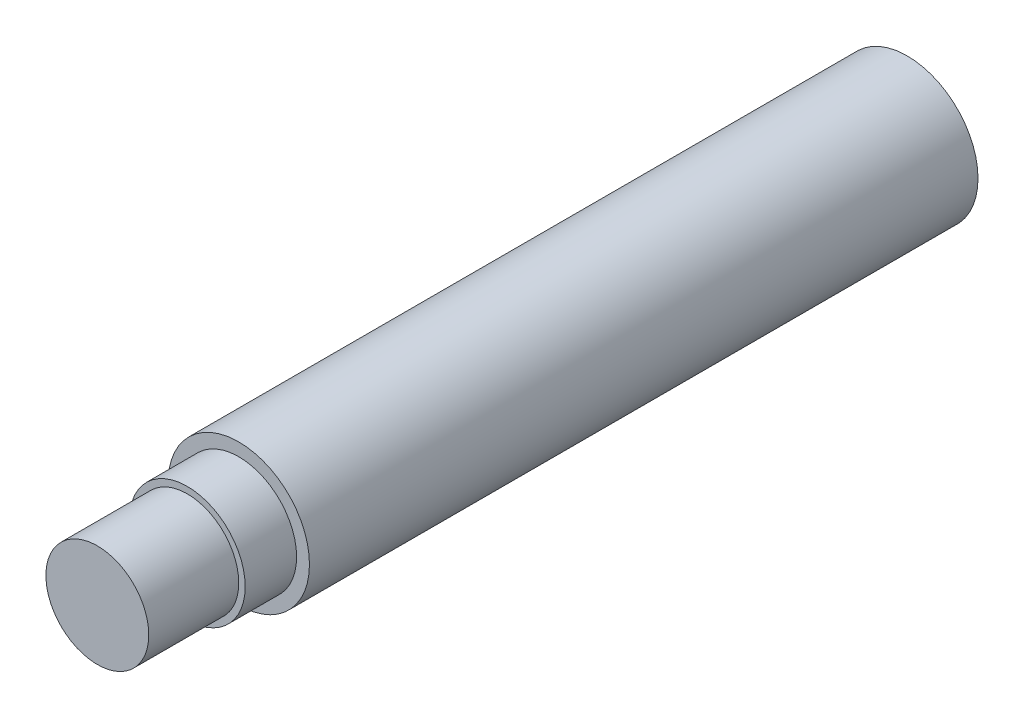
from build123d import *

# Parameters (mm, degrees)
SKETCH1_R                       = 5.5
BOSS_EXTRUDE1_DEPTH             = 52
SKETCH2_R                       = 4.5
BOSS_EXTRUDE2_DEPTH             = 4
SKETCH3_R                       = 4
BOSS_EXTRUDE3_DEPTH             = 7
F_5_0_5_DIAMETER_HOLE1_D        = 5
F_5_0_5_DIAMETER_HOLE1_DEPTH    = 45
F_5_0_5_DIAMETER_HOLE1_TIP      = 1.502151548
M8X1_0_TAPPED_HOLE1_D           = 7
M8X1_0_TAPPED_HOLE1_DEPTH       = 6
M8X1_0_TAPPED_HOLE1_CSINK_D     = 8.05
M8X1_0_TAPPED_HOLE1_CSINK_ANGLE = 90
M8X1_0_TAPPED_HOLE1_TIP         = 2.103012167


with BuildPart() as part:
    # Sketch1 → Boss-Extrude1 (new body)
    with BuildSketch(Plane.XY):
        Circle(SKETCH1_R)
    extrude(amount=BOSS_EXTRUDE1_DEPTH)

    # Sketch2 → Boss-Extrude2 (add)
    with BuildSketch(Plane.XY.offset(52)):
        Circle(SKETCH2_R)
    extrude(amount=BOSS_EXTRUDE2_DEPTH)

    # Sketch3 → Boss-Extrude3 (add)
    with BuildSketch(Plane.XY.offset(56)):
        Circle(SKETCH3_R)
    extrude(amount=BOSS_EXTRUDE3_DEPTH)

    # Ø5.0 (5) Diameter Hole1
    with Locations(Plane(origin=(0, 0, 0), x_dir=(-1, 0, 0), z_dir=(0, 0, -1))):
        with Locations((0, 0)):
            Hole(F_5_0_5_DIAMETER_HOLE1_D / 2, depth=F_5_0_5_DIAMETER_HOLE1_DEPTH)
            with Locations((0, 0, -(F_5_0_5_DIAMETER_HOLE1_DEPTH + F_5_0_5_DIAMETER_HOLE1_TIP / 2))):  # 118° drill point
                Cone(0, F_5_0_5_DIAMETER_HOLE1_D / 2, F_5_0_5_DIAMETER_HOLE1_TIP, mode=Mode.SUBTRACT)

    # M8x1.0 Tapped Hole1
    with Locations(Plane(origin=(0, 0, 0), x_dir=(-1, 0, 0), z_dir=(0, 0, -1))):
        with Locations((0, 0)):
            CounterSinkHole(M8X1_0_TAPPED_HOLE1_D / 2, M8X1_0_TAPPED_HOLE1_CSINK_D / 2, depth=M8X1_0_TAPPED_HOLE1_DEPTH, counter_sink_angle=M8X1_0_TAPPED_HOLE1_CSINK_ANGLE)
            with Locations((0, 0, -(M8X1_0_TAPPED_HOLE1_DEPTH + M8X1_0_TAPPED_HOLE1_TIP / 2))):  # 118° drill point
                Cone(0, M8X1_0_TAPPED_HOLE1_D / 2, M8X1_0_TAPPED_HOLE1_TIP, mode=Mode.SUBTRACT)


solid = part.part
